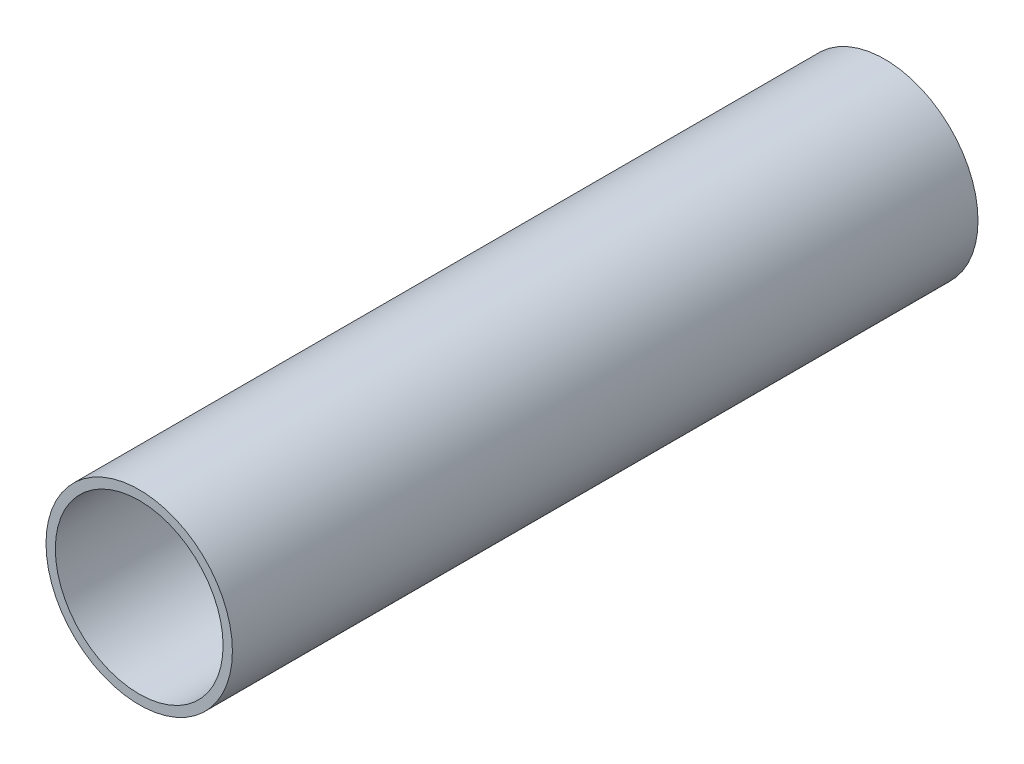
from build123d import *

# Parameters (mm, degrees)
SKETCH1_R           = 50
SKETCH1_R_2         = 45
BOSS_EXTRUDE1_DEPTH = 400


with BuildPart() as part:
    # Sketch1 → Boss-Extrude1 (new body)
    with BuildSketch(Plane.XY):
        Circle(SKETCH1_R)
        Circle(SKETCH1_R_2, mode=Mode.SUBTRACT)
    extrude(amount=BOSS_EXTRUDE1_DEPTH)


solid = part.part
